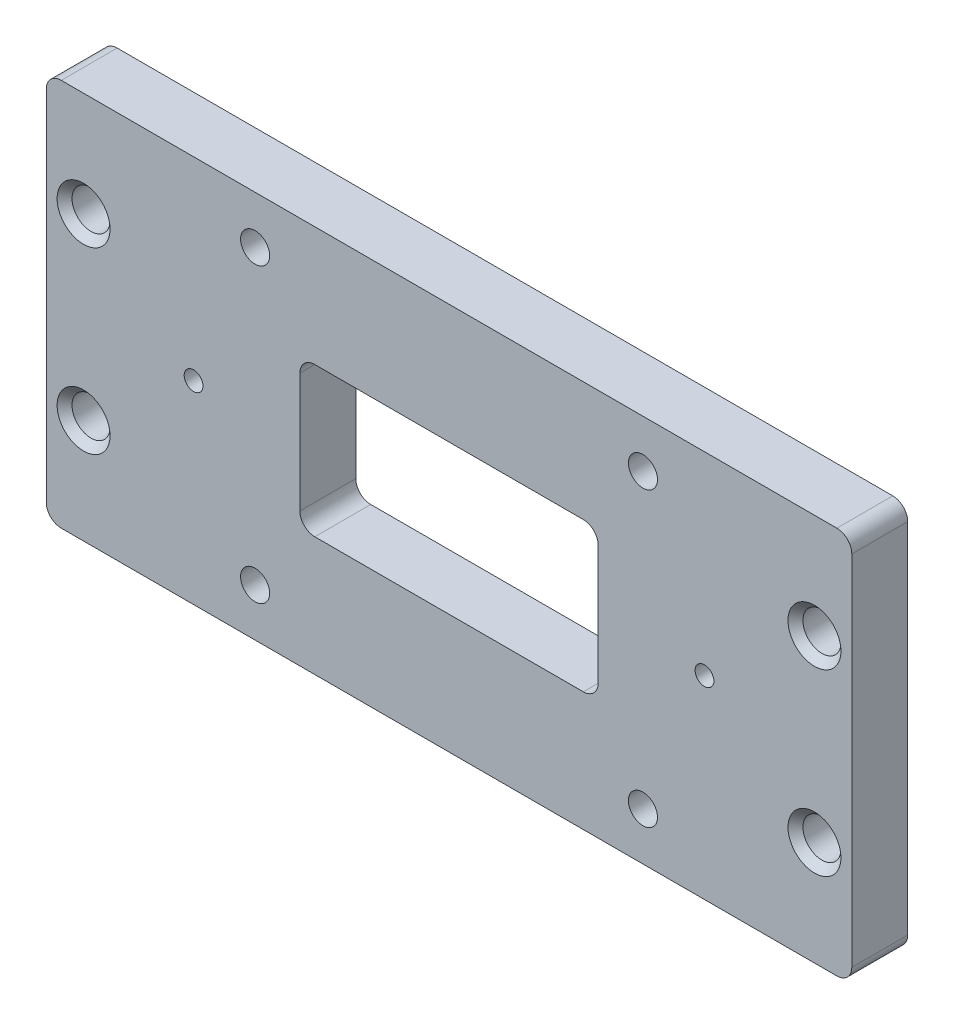
from build123d import *

# Parameters (mm, degrees)
SKETCH1_W           = 137.16
SKETCH1_H           = 66.04
BOSS_EXTRUDE1_DEPTH = 9.525
SKETCH3_R           = 2.4765
CUT_EXTRUDE1_DEPTH  = 10.525
CUT_EXTRUDE2_REACH  = 11.525
SKETCH4_R           = 3.2385
CUT_EXTRUDE3_REACH  = 11.525
SKETCH5_R           = 1.6
CUT_EXTRUDE4_REACH  = 11.525
SKETCH6_W           = 50.8
SKETCH6_H           = 25.4
FILLET1_R           = 2.54
FILLET2_R           = 2.54
CHAMFER1_SIZE       = 1.27


with BuildPart() as part:
    # Sketch1 → Boss-Extrude1 (new body)
    with BuildSketch(Plane.XY):
        Rectangle(SKETCH1_W, SKETCH1_H)
    extrude(amount=BOSS_EXTRUDE1_DEPTH)

    # Sketch3 → Cut-Extrude1 (cut, through all)
    with BuildSketch(Plane.XY.offset(9.525)):
        with Locations((-33.02, 24.892)):
            Circle(SKETCH3_R)
        with Locations((33.02, 24.892)):
            Circle(SKETCH3_R)
        with Locations((33.02, -24.892)):
            Circle(SKETCH3_R)
        with Locations((-33.02, -24.892)):
            Circle(SKETCH3_R)
    extrude(amount=-CUT_EXTRUDE1_DEPTH, mode=Mode.SUBTRACT)

    # Sketch4 → Cut-Extrude2 (cut, up to next)
    with BuildSketch(Plane.XY.offset(9.525), mode=Mode.PRIVATE) as cut_extrude2_sk1:
        with Locations((-62.23, 15.24)):
            Circle(SKETCH4_R)
    cut_extrude2_tool1 = extrude(cut_extrude2_sk1.sketch, amount=-CUT_EXTRUDE2_REACH, mode=Mode.PRIVATE) & part.part
    add(cut_extrude2_tool1.solids().sort_by_distance((-62.23, 15.24, 9.525))[0], mode=Mode.SUBTRACT)
    # Sketch4 → Cut-Extrude2 (cut, up to next)
    with BuildSketch(Plane.XY.offset(9.525), mode=Mode.PRIVATE) as cut_extrude2_sk2:
        with Locations((62.23, 15.24)):
            Circle(SKETCH4_R)
    cut_extrude2_tool2 = extrude(cut_extrude2_sk2.sketch, amount=-CUT_EXTRUDE2_REACH, mode=Mode.PRIVATE) & part.part
    add(cut_extrude2_tool2.solids().sort_by_distance((62.23, 15.24, 9.525))[0], mode=Mode.SUBTRACT)
    # Sketch4 → Cut-Extrude2 (cut, up to next)
    with BuildSketch(Plane.XY.offset(9.525), mode=Mode.PRIVATE) as cut_extrude2_sk3:
        with Locations((62.23, -15.24)):
            Circle(SKETCH4_R)
    cut_extrude2_tool3 = extrude(cut_extrude2_sk3.sketch, amount=-CUT_EXTRUDE2_REACH, mode=Mode.PRIVATE) & part.part
    add(cut_extrude2_tool3.solids().sort_by_distance((62.23, -15.24, 9.525))[0], mode=Mode.SUBTRACT)
    # Sketch4 → Cut-Extrude2 (cut, up to next)
    with BuildSketch(Plane.XY.offset(9.525), mode=Mode.PRIVATE) as cut_extrude2_sk4:
        with Locations((-62.23, -15.24)):
            Circle(SKETCH4_R)
    cut_extrude2_tool4 = extrude(cut_extrude2_sk4.sketch, amount=-CUT_EXTRUDE2_REACH, mode=Mode.PRIVATE) & part.part
    add(cut_extrude2_tool4.solids().sort_by_distance((-62.23, -15.24, 9.525))[0], mode=Mode.SUBTRACT)

    # Sketch5 → Cut-Extrude3 (cut, up to next)
    with BuildSketch(Plane.XY.offset(9.525), mode=Mode.PRIVATE) as cut_extrude3_sk1:
        with Locations((-43.5, 0)):
            Circle(SKETCH5_R)
    cut_extrude3_tool1 = extrude(cut_extrude3_sk1.sketch, amount=-CUT_EXTRUDE3_REACH, mode=Mode.PRIVATE) & part.part
    add(cut_extrude3_tool1.solids().sort_by_distance((-43.5, 0, 9.525))[0], mode=Mode.SUBTRACT)
    # Sketch5 → Cut-Extrude3 (cut, up to next)
    with BuildSketch(Plane.XY.offset(9.525), mode=Mode.PRIVATE) as cut_extrude3_sk2:
        with Locations((43.5, 0)):
            Circle(SKETCH5_R)
    cut_extrude3_tool2 = extrude(cut_extrude3_sk2.sketch, amount=-CUT_EXTRUDE3_REACH, mode=Mode.PRIVATE) & part.part
    add(cut_extrude3_tool2.solids().sort_by_distance((43.5, 0, 9.525))[0], mode=Mode.SUBTRACT)

    # Sketch6 → Cut-Extrude4 (cut, up to next)
    with BuildSketch(Plane.XY.offset(9.525), mode=Mode.PRIVATE) as cut_extrude4_sk1:
        Rectangle(SKETCH6_W, SKETCH6_H)
    cut_extrude4_tool1 = extrude(cut_extrude4_sk1.sketch, amount=-CUT_EXTRUDE4_REACH, mode=Mode.PRIVATE) & part.part
    add(cut_extrude4_tool1.solids().sort_by_distance((0, 0, 9.525))[0], mode=Mode.SUBTRACT)

    # Fillet1
    fillet1_edges = [part.edges().sort_by_distance(p)[0] for p in [
        (68.58, -33.02, 4.7625),
        (-68.58, -33.02, 4.7625),
        (-68.58, 33.02, 4.7625),
        (68.58, 33.02, 4.7625),
    ]]
    fillet(fillet1_edges, radius=FILLET1_R)

    # Fillet2
    fillet2_edges = [part.edges().sort_by_distance(p)[0] for p in [
        (25.4, 12.7, 4.7625),
        (25.4, -12.7, 4.7625),
        (-25.4, -12.7, 4.7625),
        (-25.4, 12.7, 4.7625),
    ]]
    fillet(fillet2_edges, radius=FILLET2_R)

    # Chamfer1
    chamfer1_edges = [part.edges().sort_by_distance(p)[0] for p in [
        (-65.4685, 15.24, 0),
        (-65.4685, 15.24, 9.525),
        (58.9915, 15.24, 0),
        (58.9915, 15.24, 9.525),
        (58.9915, -15.24, 0),
        (58.9915, -15.24, 9.525),
        (-65.4685, -15.24, 0),
        (-65.4685, -15.24, 9.525),
    ]]
    chamfer(chamfer1_edges, length=CHAMFER1_SIZE)


solid = part.part
